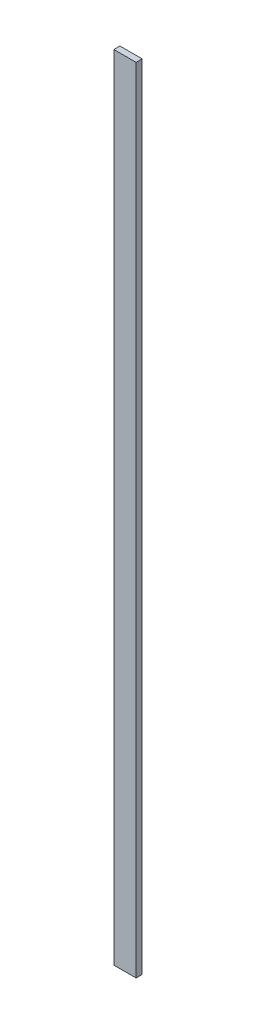
from build123d import *

# Parameters (mm, degrees)
SKETCH1_W           = 139.7
SKETCH1_H           = 38.1
BOSS_EXTRUDE1_DEPTH = 4978.4


with BuildPart() as part:
    # Sketch1 → Boss-Extrude1 (new body)
    with BuildSketch(Plane(origin=(0, 0, 0), x_dir=(1, 0, 0), z_dir=(0, 1, 0))):
        Rectangle(SKETCH1_W, SKETCH1_H)
    extrude(amount=BOSS_EXTRUDE1_DEPTH)


solid = part.part
